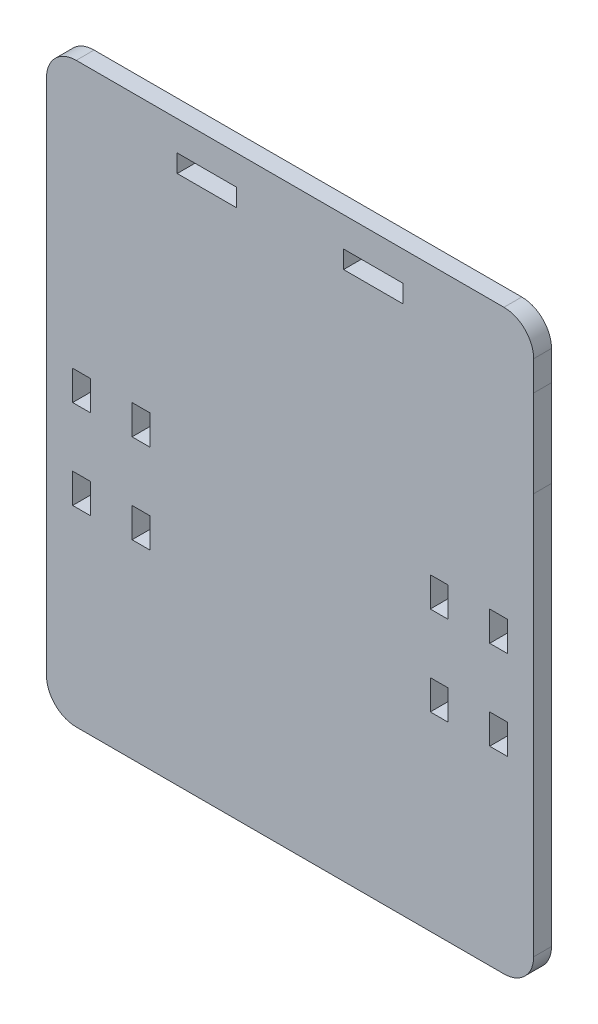
from build123d import *

# Parameters (mm, degrees)
MODEL_W                 = 10
MODEL_H                 = 3
MODEL_W_2               = 3
MODEL_H_2               = 5
SALIENTE_EXTRUIR1_DEPTH = 3


with BuildPart() as part:
    # Model → Saliente-Extruir1 (new body)
    with BuildSketch(Plane.XY):
        with BuildLine():
            Line((91.780211275, 65.839195147), (91.780211275, 57.379955116))
            Line((91.780211275, 57.379955116), (91.780211275, 13.141428354))
            Line((91.780211275, 13.141428354), (91.780211275, 3.638851328))
            Line((91.780211275, 3.638851328), (91.780211275, -1.666158522))
            ThreePointArc((91.780211275, -1.666158522), (90.315745044, -5.201692177), (86.780211275, -6.666158134))
            Line((86.780211275, -6.666158134), (14.78327762, -6.666158134))
            ThreePointArc((14.78327762, -6.666158134), (11.247743714, -5.20169204), (9.78327762, -1.666158134))
            Line((9.78327762, -1.666158134), (9.78327762, 23.733841478))
            Line((9.78327762, 23.733841478), (9.78327762, 46.933841478))
            Line((9.78327762, 46.933841478), (9.78327762, 77.517630631))
            Line((9.78327762, 77.517630631), (9.78327762, 85.517630631))
            ThreePointArc((9.78327762, 85.517630631), (11.247743714, 89.053164537), (14.78327762, 90.517630631))
            Line((14.78327762, 90.517630631), (86.780211275, 90.517630631))
            ThreePointArc((86.780211275, 90.517630631), (90.315745181, 89.053164537), (91.780211275, 85.517630631))
            Line((91.780211275, 85.517630631), (91.77714493, 80.517630631))
            Line((91.77714493, 80.517630631), (91.780211275, 65.839195147))
        make_face()
        with Locations((64.780211275, 84.017630631)):
            Rectangle(MODEL_W, MODEL_H, mode=Mode.SUBTRACT)
        with Locations((36.780211275, 84.017630631)):
            Rectangle(MODEL_W, MODEL_H, mode=Mode.SUBTRACT)
        with Locations((75.880211275, 42.833841478)):
            Rectangle(MODEL_W_2, MODEL_H_2, mode=Mode.SUBTRACT)
        with Locations((75.880211275, 27.833841478)):
            Rectangle(MODEL_W_2, MODEL_H_2, mode=Mode.SUBTRACT)
        with Locations((15.68327762, 42.833841478)):
            Rectangle(MODEL_W_2, MODEL_H_2, mode=Mode.SUBTRACT)
        with Locations((15.68327762, 27.833841478)):
            Rectangle(MODEL_W_2, MODEL_H_2, mode=Mode.SUBTRACT)
        with Locations((85.880211275, 42.833841478)):
            Rectangle(MODEL_W_2, MODEL_H_2, mode=Mode.SUBTRACT)
        with Locations((85.880211275, 27.833841478)):
            Rectangle(MODEL_W_2, MODEL_H_2, mode=Mode.SUBTRACT)
        with Locations((25.68327762, 42.833841478)):
            Rectangle(MODEL_W_2, MODEL_H_2, mode=Mode.SUBTRACT)
        with Locations((25.68327762, 27.833841478)):
            Rectangle(MODEL_W_2, MODEL_H_2, mode=Mode.SUBTRACT)
    extrude(amount=SALIENTE_EXTRUIR1_DEPTH)


solid = part.part
